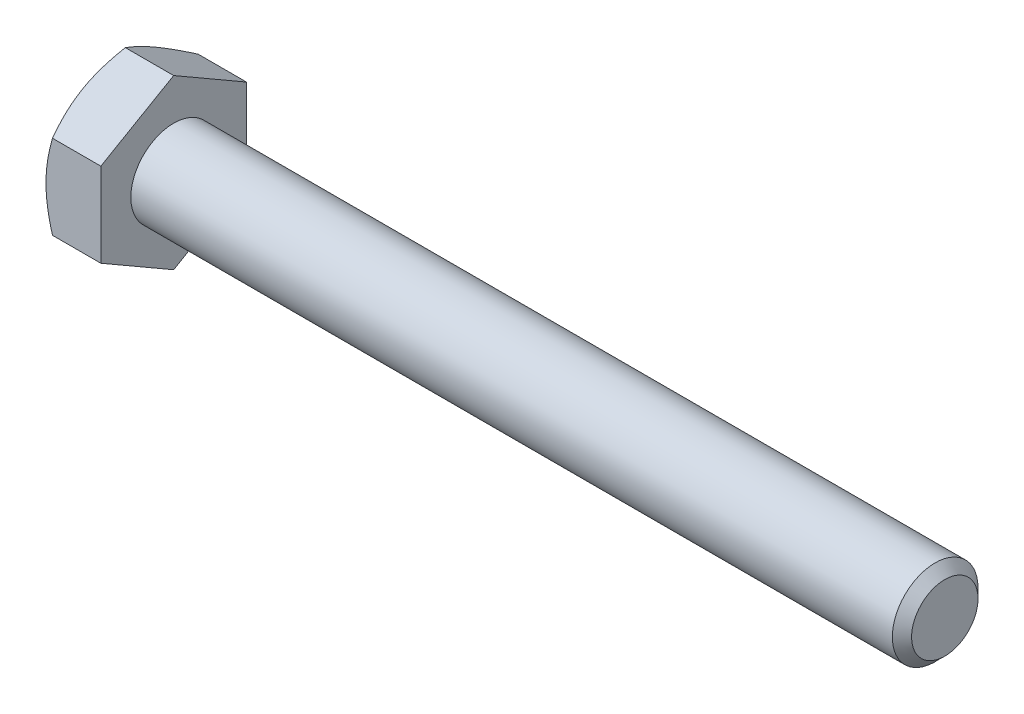
from build123d import *

# Parameters (mm, degrees)
SKETCH2_R           = 5
BOSS_EXTRUDE1_DEPTH = 90
CHAMFER1_SIZE       = 1.125
BOSS_EXTRUDE2_DEPTH = 6.4
SKETCH6_OUTSIDE_W   = 376.37
SKETCH6_OUTSIDE_H   = 379
SKETCH6_OUTSIDE_R   = 8.5
CUT_EXTRUDE1_DEPTH  = 97.4
CUT_EXTRUDE1_TAPER  = 60
SKETCH7_W           = 0.395125951
SKETCH7_H           = 0.395125952
CUT_EXTRUDE2_DEPTH  = 0.25


with BuildPart() as part:
    # Sketch2 → Boss-Extrude1 (new body)
    with BuildSketch(Plane(origin=(48.2, 0, 0), x_dir=(0, 0, -1), z_dir=(1, 0, 0))):
        Circle(SKETCH2_R)
    extrude(amount=-BOSS_EXTRUDE1_DEPTH)

    # Chamfer1
    chamfer1_edges = [part.edges().sort_by_distance(p)[0] for p in [
        (48.2, 0, 5),
    ]]
    chamfer(chamfer1_edges, length=CHAMFER1_SIZE)

    # Sketch3 → Boss-Extrude2 (add)
    with BuildSketch(Plane.ZY.offset(41.8)):
        Polygon((-8.5, -4.907477288), (0, -9.814954576), (8.5, -4.907477288), (8.5, 4.907477288), (0, 9.814954576), (-8.5, 4.907477288), align=None)
    extrude(amount=BOSS_EXTRUDE2_DEPTH)

    # Sketch6 outside → Cut-Extrude1 (cut, through all)
    with BuildSketch(Plane.ZY.offset(48.2)):
        Rectangle(SKETCH6_OUTSIDE_W, SKETCH6_OUTSIDE_H)
        Circle(SKETCH6_OUTSIDE_R, mode=Mode.SUBTRACT)
    extrude(amount=-CUT_EXTRUDE1_DEPTH, taper=CUT_EXTRUDE1_TAPER, mode=Mode.SUBTRACT)

    # Sketch7 → Cut-Extrude2 (cut)
    with BuildSketch(Plane.ZY.offset(48.2)):
        with BuildLine():
            Line((-2.568318685, 4.25), (-2.963444636, 4.25))
            Line((-2.963444636, 4.25), (-2.963444636, 6.651624924))
            add(Edge.make_bspline(
                [(-2.963444636, 6.651624924), (-2.986196024, 6.62968401), (-3.033482289, 6.584082225), (-3.113414724, 6.519544312), (-3.202629538, 6.454132402), (-3.299968218, 6.391231537), (-3.399188536, 6.332017157), (-3.495072199, 6.278762925), (-3.586018389, 6.233696924), (-3.645925135, 6.209054656), (-3.674671349, 6.19723008)],
                knots=[0, 0, 0, 0, 9.4782e-05, 0.000196994, 0.000307885, 0.000426554, 0.000544505, 0.000654483, 0.00075554, 0.000848767, 0.000848767, 0.000848767, 0.000848767], degree=3))
            Line((-3.674671349, 6.19723008), (-3.674671349, 6.561486816))
            add(Edge.make_bspline(
                [(-3.674671349, 6.561486816), (-3.625296755, 6.586914831), (-3.527982354, 6.637031942), (-3.390498149, 6.723591083), (-3.262141854, 6.817424755), (-3.145038274, 6.918512183), (-3.040062377, 7.021841681), (-2.951597664, 7.126105204), (-2.877576021, 7.2274809), (-2.840437961, 7.298179205), (-2.822681016, 7.331982422)],
                knots=[0, 0, 0, 0, 0.000166548, 0.000328257, 0.00048681, 0.000643105, 0.000791972, 0.000928179, 0.001053059, 0.001167473, 0.001167473, 0.001167473, 0.001167473], degree=3))
            Line((-2.822681016, 7.331982422), (-2.568318685, 7.331982422))
            Line((-2.568318685, 7.331982422), (-2.568318685, 4.25))
        make_face()
        with BuildLine():
            add(Edge.make_bspline(
                [(-1.580503806, 5.770000145), (-1.580105717, 5.814044503), (-1.579326027, 5.900308852), (-1.574489865, 6.026529092), (-1.566046319, 6.146395227), (-1.553442429, 6.25980316), (-1.538517061, 6.367008875), (-1.519113989, 6.467859377), (-1.497282713, 6.562580942), (-1.471089099, 6.651074836), (-1.442310892, 6.734101948), (-1.409661098, 6.811529082), (-1.372925651, 6.883274147), (-1.333909869, 6.950081181), (-1.290559882, 7.010911058), (-1.245492208, 7.067470914), (-1.195431598, 7.117686479), (-1.142459679, 7.162849803), (-1.085796427, 7.202703805), (-1.025741645, 7.237093001), (-0.962526408, 7.267456182), (-0.894945905, 7.290313577), (-0.824403092, 7.308947199), (-0.750354969, 7.322654317), (-0.672719934, 7.330735126), (-0.619667301, 7.33156196), (-0.592688927, 7.331982422)],
                knots=[0, 0, 0, 0, 0.000132133, 0.000258793, 0.000378877, 0.000492531, 0.000601059, 0.000703497, 0.000800536, 0.000892551, 0.000980222, 0.001064046, 0.001144393, 0.001221899, 0.001295895, 0.001368308, 0.001438595, 0.001508239, 0.001576924, 0.001646074, 0.001715672, 0.001786939, 0.001859717, 0.001934431, 0.002012634, 0.002093549, 0.002093549, 0.002093549, 0.002093549], degree=3))
            add(Edge.make_bspline(
                [(-0.592688927, 7.331982422), (-0.553108144, 7.330818775), (-0.475350106, 7.328532744), (-0.361822971, 7.309888287), (-0.254830962, 7.277994072), (-0.154443593, 7.234967399), (-0.06237697, 7.180315243), (0.019842406, 7.113877221), (0.091327664, 7.036350919), (0.151298654, 6.946817676), (0.203719286, 6.847747416), (0.250288624, 6.738695476), (0.292385953, 6.61978406), (0.322259135, 6.513341743), (0.34356765, 6.421456958), (0.357672195, 6.345672987), (0.369381794, 6.263901655), (0.37835293, 6.17634079), (0.385713535, 6.083088599), (0.391397793, 5.98408702), (0.394283136, 5.879088618), (0.394839746, 5.807044656), (0.395125952, 5.770000145)],
                knots=[0, 0, 0, 0, 0.000118698, 0.000233188, 0.000343948, 0.000452902, 0.000560053, 0.000664091, 0.000768955, 0.000875126, 0.000986437, 0.001104794, 0.001230547, 0.001364623, 0.00143621, 0.001513465, 0.001595799, 0.001683956, 0.001777475, 0.001876412, 0.001981413, 0.002092549, 0.002092549, 0.002092549, 0.002092549], degree=3))
            add(Edge.make_bspline(
                [(0.395125952, 5.770000145), (0.394720405, 5.72616267), (0.393928091, 5.640517533), (0.389221516, 5.515309367), (0.380269187, 5.396347563), (0.369253182, 5.283359615), (0.352588275, 5.176647146), (0.334630934, 5.075756765), (0.312422139, 4.981146602), (0.286509689, 4.892775193), (0.257326387, 4.81017526), (0.22532238, 4.73272256), (0.189874869, 4.660470016), (0.149928803, 4.594122345), (0.107311894, 4.532798891), (0.061712021, 4.476269617), (0.01216241, 4.425348143), (-0.041286868, 4.380320284), (-0.097552273, 4.339759529), (-0.157753059, 4.305030807), (-0.221625737, 4.276258665), (-0.288743547, 4.251659912), (-0.359787497, 4.233635389), (-0.434197342, 4.219837898), (-0.512247246, 4.211712937), (-0.565505082, 4.210901552), (-0.592688927, 4.210487405)],
                knots=[0, 0, 0, 0, 0.000131516, 0.000256942, 0.000375795, 0.000489383, 0.00059739, 0.000699714, 0.000796754, 0.000888769, 0.000975857, 0.001059441, 0.001140064, 0.001217039, 0.001291541, 0.001363954, 0.001434681, 0.001504326, 0.001573368, 0.001642518, 0.001712416, 0.001783308, 0.001856683, 0.001932004, 0.002010207, 0.002091739, 0.002091739, 0.002091739, 0.002091739], degree=3))
            add(Edge.make_bspline(
                [(-0.592688927, 4.210487405), (-0.6283301, 4.211504071), (-0.697820578, 4.213486291), (-0.799306296, 4.226954252), (-0.894556056, 4.250658495), (-0.984373234, 4.282449228), (-1.067748262, 4.324971164), (-1.145079221, 4.376707402), (-1.217920022, 4.436454245), (-1.259851615, 4.483593132), (-1.281072421, 4.507449253)],
                knots=[0, 0, 0, 0, 0.000106922, 0.000208468, 0.000306397, 0.000400919, 0.000493691, 0.000586328, 0.000679683, 0.000775338, 0.000775338, 0.000775338, 0.000775338], degree=3))
            add(Edge.make_bspline(
                [(-1.281072421, 4.507449253), (-1.305498056, 4.54268359), (-1.355864762, 4.615338302), (-1.414814624, 4.739221326), (-1.467398945, 4.875599141), (-1.508667995, 5.027147464), (-1.540991949, 5.192660143), (-1.564337915, 5.372461948), (-1.577549433, 5.566475199), (-1.579496784, 5.700627011), (-1.580503806, 5.770000145)],
                knots=[0, 0, 0, 0, 0.000128428, 0.000264824, 0.000410212, 0.000566594, 0.000735258, 0.00091583, 0.001110164, 0.001318281, 0.001318281, 0.001318281, 0.001318281], degree=3))
        make_face()
        with BuildLine():
            add(Edge.make_bspline(
                [(-1.185377855, 5.771234913), (-1.184985526, 5.711957182), (-1.184234522, 5.598486491), (-1.176388355, 5.436374033), (-1.162881502, 5.290126467), (-1.145024559, 5.159946283), (-1.121446166, 5.045657386), (-1.091840703, 4.94755102), (-1.058468306, 4.864449686), (-1.017170596, 4.79738336), (-0.971954166, 4.742714521), (-0.925271291, 4.695697552), (-0.876023686, 4.655734205), (-0.824532686, 4.622412923), (-0.769999369, 4.597184238), (-0.71302005, 4.57889843), (-0.653582329, 4.568375229), (-0.61310254, 4.566863243), (-0.592688927, 4.566100761)],
                knots=[0, 0, 0, 0, 0.000177824, 0.000340394, 0.000486729, 0.000618307, 0.000734429, 0.000836378, 0.000925472, 0.001002239, 0.001071568, 0.001137924, 0.001200694, 0.001261493, 0.001321431, 0.001380396, 0.001440587, 0.001501821, 0.001501821, 0.001501821, 0.001501821], degree=3))
            add(Edge.make_bspline(
                [(-0.592688927, 4.566100761), (-0.572280426, 4.566879903), (-0.531810774, 4.568424926), (-0.472235717, 4.578716081), (-0.415478091, 4.597943229), (-0.361026084, 4.623082807), (-0.309160831, 4.655644596), (-0.260155096, 4.695758894), (-0.213226305, 4.742747946), (-0.168212986, 4.798052211), (-0.127229907, 4.865428606), (-0.093231484, 4.948462246), (-0.064087407, 5.046740426), (-0.040379634, 5.160971093), (-0.022449029, 5.290945453), (-0.009023839, 5.436787394), (-0.001125164, 5.598691266), (-0.000386554, 5.711956914), (0, 5.771234913)],
                knots=[0, 0, 0, 0, 6.1233e-05, 0.000121424, 0.00018058, 0.000240518, 0.000300987, 0.000363757, 0.000430113, 0.000499921, 0.000577215, 0.000665741, 0.00076828, 0.000884403, 0.00101537, 0.001161704, 0.001323658, 0.001501482, 0.001501482, 0.001501482, 0.001501482], degree=3))
            add(Edge.make_bspline(
                [(0, 5.771234913), (-0.000374177, 5.829279529), (-0.001091087, 5.940490817), (-0.00919348, 6.099480175), (-0.021890658, 6.243273035), (-0.03925838, 6.372001961), (-0.06234008, 6.4855272), (-0.090335034, 6.584090432), (-0.123695207, 6.667481456), (-0.163360333, 6.736537934), (-0.207515555, 6.79318298), (-0.253639871, 6.842214197), (-0.302886392, 6.883913649), (-0.356127619, 6.917365565), (-0.411647487, 6.944353326), (-0.470721702, 6.962926991), (-0.53276961, 6.974338069), (-0.575352285, 6.975684332), (-0.597010617, 6.976369066)],
                knots=[0, 0, 0, 0, 0.00017412, 0.000333607, 0.000477426, 0.000607084, 0.00072308, 0.000824677, 0.000914104, 0.00099183, 0.001062711, 0.001129091, 0.001193515, 0.001255687, 0.001317268, 0.001378186, 0.001440917, 0.001505848, 0.001505848, 0.001505848, 0.001505848], degree=3))
            add(Edge.make_bspline(
                [(-0.597010617, 6.976369066), (-0.617422948, 6.975833322), (-0.65767345, 6.974776906), (-0.716605455, 6.964693418), (-0.772454624, 6.94783158), (-0.825860807, 6.924990582), (-0.875490749, 6.894251111), (-0.923312648, 6.858360591), (-0.967086713, 6.814631997), (-0.99346458, 6.781941185), (-1.006953792, 6.765223635)],
                knots=[0, 0, 0, 0, 6.1199e-05, 0.000120676, 0.000178688, 0.000235922, 0.000294368, 0.000353392, 0.000414948, 0.000479372, 0.000479372, 0.000479372, 0.000479372], degree=3))
            add(Edge.make_bspline(
                [(-1.006953792, 6.765223635), (-1.021639429, 6.740670733), (-1.052652401, 6.688820173), (-1.087354113, 6.598701764), (-1.118008235, 6.495713576), (-1.14324674, 6.378271061), (-1.161505027, 6.24657568), (-1.175919239, 6.100780372), (-1.183406886, 5.94068159), (-1.184702739, 5.829275502), (-1.185377855, 5.771234913)],
                knots=[0, 0, 0, 0, 8.5692e-05, 0.000180963, 0.000288589, 0.000407988, 0.000540876, 0.000687269, 0.000847373, 0.001021503, 0.001021503, 0.001021503, 0.001021503], degree=3))
        make_face(mode=Mode.SUBTRACT)
        with Locations((1.185377854, 4.447562976)):
            Rectangle(SKETCH7_W, SKETCH7_H)
        with BuildLine():
            Line((2.015142353, 5.000739308), (2.410268304, 5.040251903))
            add(Edge.make_bspline(
                [(2.410268304, 5.040251903), (2.413840479, 5.020007204), (2.420745795, 4.980872485), (2.436328917, 4.925098804), (2.452134025, 4.873095247), (2.47253629, 4.826020329), (2.493783762, 4.782595367), (2.517845941, 4.74325551), (2.545151535, 4.708790889), (2.583710618, 4.668404495), (2.638420343, 4.626260608), (2.714255437, 4.592122416), (2.797681164, 4.569168901), (2.856473329, 4.567146852), (2.886888983, 4.566100761)],
                knots=[0, 0, 0, 0, 6.163e-05, 0.000119137, 0.00017361, 0.000224521, 0.000272839, 0.000318584, 0.000362552, 0.000404471, 0.000485968, 0.000567724, 0.000652632, 0.000743641, 0.000743641, 0.000743641, 0.000743641], degree=3))
            add(Edge.make_bspline(
                [(2.886888983, 4.566100761), (2.913502977, 4.567059155), (2.965883441, 4.568945423), (3.042255893, 4.583567924), (3.114884907, 4.606992865), (3.182506216, 4.640602748), (3.244873712, 4.681505039), (3.299349616, 4.7301052), (3.346661352, 4.784310082), (3.385518984, 4.846764506), (3.418685022, 4.918097941), (3.450022517, 4.9992176), (3.479667267, 5.091521035), (3.506013778, 5.193830946), (3.529605789, 5.302412185), (3.546162435, 5.414804415), (3.556349093, 5.528822559), (3.557438834, 5.605548926), (3.557985717, 5.644053748)],
                knots=[0, 0, 0, 0, 7.9796e-05, 0.00015705, 0.000232411, 0.000308066, 0.000382894, 0.000455494, 0.00052641, 0.000598005, 0.000675326, 0.000762116, 0.000858762, 0.000965981, 0.001078956, 0.001191939, 0.001306581, 0.001422073, 0.001422073, 0.001422073, 0.001422073], degree=3))
            add(Edge.make_bspline(
                [(3.557985717, 5.644053748), (3.557798688, 5.654549729), (3.557351233, 5.67966075), (3.556581539, 5.704764073), (3.556133564, 5.719374632)],
                knots=[0, 0, 0, 0, 3.1493e-05, 7.5344e-05, 7.5344e-05, 7.5344e-05, 7.5344e-05], degree=3))
            add(Edge.make_bspline(
                [(3.556133564, 5.719374632), (3.537085168, 5.69044826), (3.499019071, 5.632642126), (3.428891918, 5.555059298), (3.348665223, 5.486242275), (3.259556771, 5.426725431), (3.16376686, 5.377881138), (3.062961935, 5.342388897), (2.95801097, 5.320472904), (2.886583026, 5.318060151), (2.85046331, 5.316840069)],
                knots=[0, 0, 0, 0, 0.000103787, 0.000207406, 0.000312474, 0.000420179, 0.000528136, 0.000634163, 0.000739986, 0.000848242, 0.000848242, 0.000848242, 0.000848242], degree=3))
            add(Edge.make_bspline(
                [(2.85046331, 5.316840069), (2.820363425, 5.317619924), (2.761111224, 5.319155084), (2.674317174, 5.332799095), (2.59083831, 5.353260274), (2.511465687, 5.38423949), (2.43496438, 5.42255281), (2.362137653, 5.469579471), (2.292873286, 5.525255467), (2.228066286, 5.588887534), (2.168924197, 5.659813801), (2.1167677, 5.736306369), (2.073457016, 5.818739261), (2.037421028, 5.906083595), (2.009615469, 5.999183298), (1.990294246, 6.097820225), (1.977299795, 6.201617852), (1.976193821, 6.272715691), (1.975629758, 6.308976638)],
                knots=[0, 0, 0, 0, 9.0242e-05, 0.000177642, 0.000262993, 0.000347611, 0.000432651, 0.000519305, 0.000607143, 0.000698824, 0.00079131, 0.000883778, 0.000976023, 0.001070151, 0.001166836, 0.001266969, 0.001371422, 0.001480144, 0.001480144, 0.001480144, 0.001480144], degree=3))
            add(Edge.make_bspline(
                [(1.975629758, 6.308976638), (1.976474577, 6.346465906), (1.978127192, 6.419801416), (1.990610702, 6.527027039), (2.011263538, 6.628609974), (2.041382852, 6.724356326), (2.078630372, 6.81488129), (2.12559805, 6.899532199), (2.180477352, 6.978671167), (2.24359618, 7.051535224), (2.312963199, 7.116914452), (2.386610891, 7.175266551), (2.465498944, 7.223231698), (2.548114747, 7.263222666), (2.635083515, 7.294128288), (2.726256605, 7.316466558), (2.82188631, 7.329573957), (2.887054298, 7.331169976), (2.920227735, 7.331982422)],
                knots=[0, 0, 0, 0, 0.000112447, 0.000219966, 0.00032337, 0.000422958, 0.000520648, 0.000616533, 0.000712784, 0.00080908, 0.000905158, 0.000998402, 0.001090417, 0.001181541, 0.001273322, 0.001366759, 0.001462716, 0.001562209, 0.001562209, 0.001562209, 0.001562209], degree=3))
            add(Edge.make_bspline(
                [(2.920227735, 7.331982422), (2.94432121, 7.331495139), (2.99221098, 7.330526585), (3.063480901, 7.323131988), (3.133063159, 7.309802016), (3.201411424, 7.292975846), (3.267372851, 7.269619853), (3.332218948, 7.242611039), (3.395167577, 7.209577215), (3.456585533, 7.172013619), (3.516087062, 7.130580547), (3.5708319, 7.08297843), (3.623008165, 7.032461421), (3.671554138, 6.977444063), (3.714934318, 6.917077255), (3.756093766, 6.853495263), (3.793048395, 6.785310706), (3.82674845, 6.712431238), (3.856742807, 6.633356658), (3.881765615, 6.546339503), (3.903215744, 6.451078381), (3.921075091, 6.347447023), (3.934318089, 6.235519309), (3.944064162, 6.115461586), (3.950444498, 5.987182534), (3.950982503, 5.898835628), (3.951259515, 5.853347025)],
                knots=[0, 0, 0, 0, 7.2276e-05, 0.000143661, 0.00021462, 0.000284698, 0.000354596, 0.000424314, 0.000495281, 0.000567599, 0.00064023, 0.000712485, 0.000784959, 0.000858022, 0.000932237, 0.001007762, 0.00108512, 0.001164677, 0.001248498, 0.001338562, 0.001436064, 0.001541318, 0.001653887, 0.001774066, 0.001902631, 0.002039085, 0.002039085, 0.002039085, 0.002039085], degree=3))
            add(Edge.make_bspline(
                [(3.951259515, 5.853347025), (3.95098065, 5.805800798), (3.950437151, 5.713135114), (3.944006726, 5.577866732), (3.934265553, 5.449997731), (3.921013197, 5.329444138), (3.903029348, 5.216389944), (3.881654113, 5.110854913), (3.856445668, 5.01264421), (3.826822072, 4.921749212), (3.793145767, 4.837125352), (3.756246485, 4.757730608), (3.714921334, 4.683682393), (3.669634643, 4.614838699), (3.62096792, 4.551079194), (3.568161315, 4.492574683), (3.511197678, 4.439502014), (3.450803114, 4.391263907), (3.38706826, 4.348754021), (3.320860767, 4.311244334), (3.251433446, 4.280517335), (3.179500028, 4.255310009), (3.105188338, 4.234497271), (3.027893097, 4.22047361), (2.947971408, 4.212531088), (2.893903336, 4.211174554), (2.866515301, 4.210487405)],
                knots=[0, 0, 0, 0, 0.000142628, 0.000277976, 0.000406156, 0.000527309, 0.0006417, 0.000749462, 0.000850239, 0.000945711, 0.001036051, 0.001123328, 0.001208179, 0.001290201, 0.001370342, 0.001448584, 0.001526336, 0.001603664, 0.001680205, 0.001755942, 0.001831667, 0.001907625, 0.001984462, 0.00206293, 0.002142976, 0.002225146, 0.002225146, 0.002225146, 0.002225146], degree=3))
            add(Edge.make_bspline(
                [(2.866515301, 4.210487405), (2.837465496, 4.210989678), (2.780629433, 4.211972379), (2.697654628, 4.222305542), (2.618610112, 4.238015318), (2.54372593, 4.261206667), (2.472441271, 4.289754596), (2.405972827, 4.326237225), (2.343139367, 4.368327264), (2.284716063, 4.416873494), (2.231386971, 4.471697642), (2.183134335, 4.531448544), (2.14083099, 4.596900077), (2.104698323, 4.667666359), (2.072693162, 4.743152029), (2.047880459, 4.824369304), (2.027722524, 4.910569119), (2.019403459, 4.970197213), (2.015142353, 5.000739308)],
                knots=[0, 0, 0, 0, 8.7106e-05, 0.000170423, 0.000250457, 0.000328575, 0.000405275, 0.000480416, 0.000555588, 0.000631869, 0.000707835, 0.000784681, 0.000861913, 0.000941163, 0.0010228, 0.001107546, 0.001195607, 0.001288077, 0.001288077, 0.001288077, 0.001288077], degree=3))
        make_face()
        with BuildLine():
            add(Edge.make_bspline(
                [(3.556133564, 6.317620018), (3.555689168, 6.342334996), (3.554824182, 6.390441115), (3.547245845, 6.460627345), (3.535052351, 6.526721926), (3.517937883, 6.58910491), (3.494695926, 6.647115014), (3.467771704, 6.70210662), (3.434846089, 6.752555524), (3.397695315, 6.799141057), (3.356772987, 6.840810741), (3.312208949, 6.877142978), (3.264838742, 6.908287943), (3.21352595, 6.932776261), (3.159957389, 6.952954547), (3.102846268, 6.96614229), (3.04297843, 6.975380567), (3.001760115, 6.976035124), (2.980731397, 6.976369066)],
                knots=[0, 0, 0, 0, 7.4127e-05, 0.000144284, 0.000211488, 0.000275601, 0.000337969, 0.000398712, 0.000458991, 0.000518289, 0.000577226, 0.000633827, 0.000690509, 0.000746836, 0.000804067, 0.000861867, 0.000922374, 0.000985396, 0.000985396, 0.000985396, 0.000985396], degree=3))
            add(Edge.make_bspline(
                [(2.980731397, 6.976369066), (2.959101426, 6.975713619), (2.916490327, 6.974422386), (2.854035287, 6.966106794), (2.794804377, 6.950184996), (2.73839772, 6.929065091), (2.684188839, 6.902940141), (2.634148442, 6.868708472), (2.586180661, 6.829915507), (2.54220941, 6.784910501), (2.502043122, 6.735567373), (2.466652196, 6.682349267), (2.436848552, 6.625230105), (2.413024256, 6.564448035), (2.3935543, 6.500532839), (2.380179825, 6.432913013), (2.371950319, 6.361660546), (2.371159847, 6.312909916), (2.370755709, 6.287985572)],
                knots=[0, 0, 0, 0, 6.4899e-05, 0.000127851, 0.000188499, 0.000248475, 0.000308389, 0.000368492, 0.000429914, 0.000493217, 0.000556855, 0.000620554, 0.000684619, 0.000749738, 0.000816146, 0.000884798, 0.000956249, 0.001030994, 0.001030994, 0.001030994, 0.001030994], degree=3))
            add(Edge.make_bspline(
                [(2.370755709, 6.287985572), (2.371128962, 6.265727279), (2.371860764, 6.22208742), (2.380575729, 6.158399021), (2.392200198, 6.097614263), (2.410731799, 6.040353602), (2.433056995, 5.985785726), (2.462072883, 5.935163867), (2.49474201, 5.886974334), (2.533020218, 5.84283148), (2.575336858, 5.802786174), (2.62155522, 5.767882378), (2.671091516, 5.738004124), (2.724405959, 5.713956363), (2.781178829, 5.695436051), (2.841283402, 5.681801365), (2.904980937, 5.673680208), (2.948603683, 5.672867793), (2.970853248, 5.672453425)],
                knots=[0, 0, 0, 0, 6.6723e-05, 0.000130818, 0.000192569, 0.000252123, 0.00031106, 0.000369107, 0.000426819, 0.00048548, 0.000544005, 0.000601299, 0.000658898, 0.000717197, 0.000776353, 0.000837761, 0.000901856, 0.000968579, 0.000968579, 0.000968579, 0.000968579], degree=3))
            add(Edge.make_bspline(
                [(2.970853248, 5.672453425), (2.991663789, 5.672871843), (3.032623591, 5.673695382), (3.092625396, 5.681851159), (3.149638391, 5.695511131), (3.203918555, 5.714082438), (3.255377912, 5.738121883), (3.303670426, 5.768237575), (3.349729628, 5.802742512), (3.392205347, 5.843059847), (3.431026598, 5.887699021), (3.464599762, 5.93710103), (3.493269443, 5.990368719), (3.515835399, 6.048133488), (3.533909661, 6.10968415), (3.546635142, 6.175410391), (3.554968835, 6.245171906), (3.555739449, 6.293105409), (3.556133564, 6.317620018)],
                knots=[0, 0, 0, 0, 6.2405e-05, 0.000122826, 0.000181227, 0.000238043, 0.000294661, 0.000351205, 0.000408499, 0.000467023, 0.000526555, 0.000585634, 0.000645847, 0.000707641, 0.000771331, 0.000838045, 0.00090827, 0.00098178, 0.00098178, 0.00098178, 0.00098178], degree=3))
        make_face(mode=Mode.SUBTRACT)
    extrude(amount=-CUT_EXTRUDE2_DEPTH, mode=Mode.SUBTRACT)


solid = part.part
